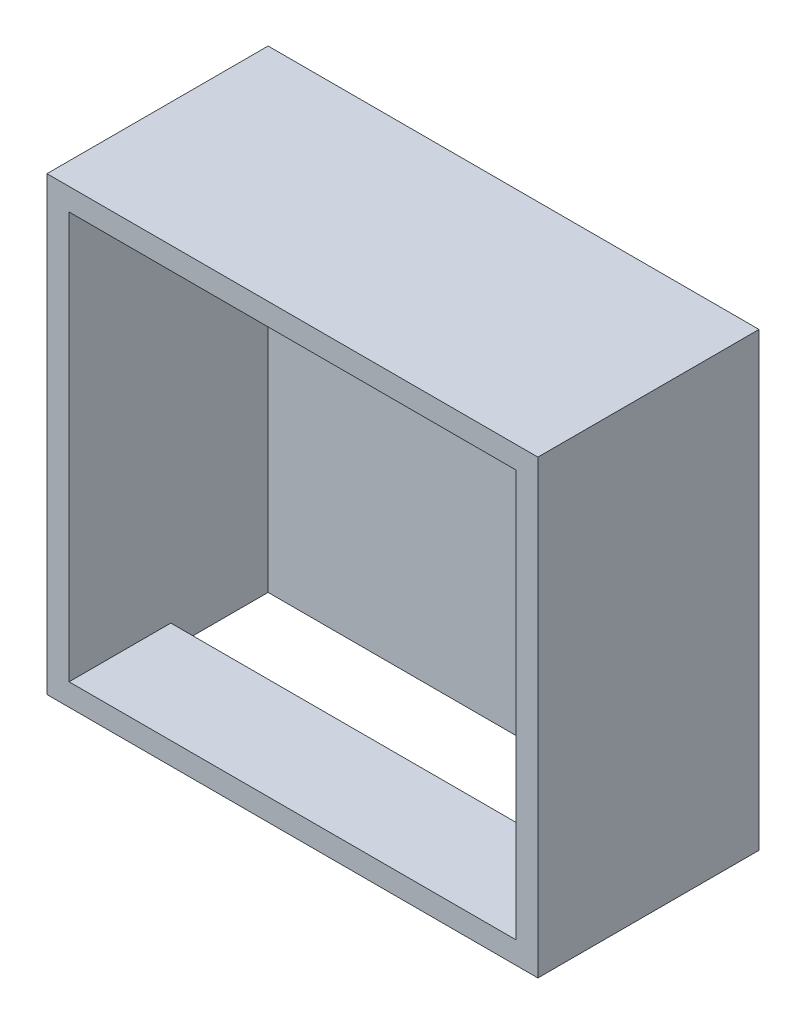
from build123d import *

# Parameters (mm, degrees)
SKETCH_1_W          = 111
SKETCH_1_H          = 102
SKETCH_1_W_2        = 101
SKETCH_1_H_2        = 92
EXTRUDE_1_DEPTH     = 45
SKETCH_2_W          = 111
SKETCH_2_H          = 102
EXTRUDE_2_DEPTH     = 5
SKETCH_3_W          = 101
SKETCH_3_H          = 22
CUT_EXTRUDE_4_DEPTH = 5
SKETCH_4_W          = 101
SKETCH_4_H          = 9
EXTRUDE_3_DEPTH     = 8


with BuildPart() as part:
    # 草圖1 → 填料-伸長1 (new body)
    with BuildSketch(Plane.XY):
        with Locations((-27.081120075, 1.427877732)):
            Rectangle(SKETCH_1_W, SKETCH_1_H)
        with Locations((-27.081120075, 1.427877732)):
            Rectangle(SKETCH_1_W_2, SKETCH_1_H_2, mode=Mode.SUBTRACT)
    extrude(amount=EXTRUDE_1_DEPTH)

    # 草圖2 → 填料-伸長2 (add)
    with BuildSketch(Plane(origin=(0, 0, 0), x_dir=(-1, 0, 0), z_dir=(0, 0, -1))):
        with Locations((27.081120075, 1.427877732)):
            Rectangle(SKETCH_2_W, SKETCH_2_H)
    extrude(amount=EXTRUDE_2_DEPTH)

    # 草圖3 → 除料-伸長4 (cut)
    with BuildSketch(Plane.XZ.offset(49.572122268)):
        with Locations((-27.081120075, 11)):
            Rectangle(SKETCH_3_W, SKETCH_3_H)
    extrude(amount=-CUT_EXTRUDE_4_DEPTH, mode=Mode.SUBTRACT)

    # 草圖4 → 填料-伸長3 (add)
    with BuildSketch(Plane.XY):
        with Locations((-27.081120075, 42.927877732)):
            Rectangle(SKETCH_4_W, SKETCH_4_H)
    extrude(amount=EXTRUDE_3_DEPTH)


solid = part.part
